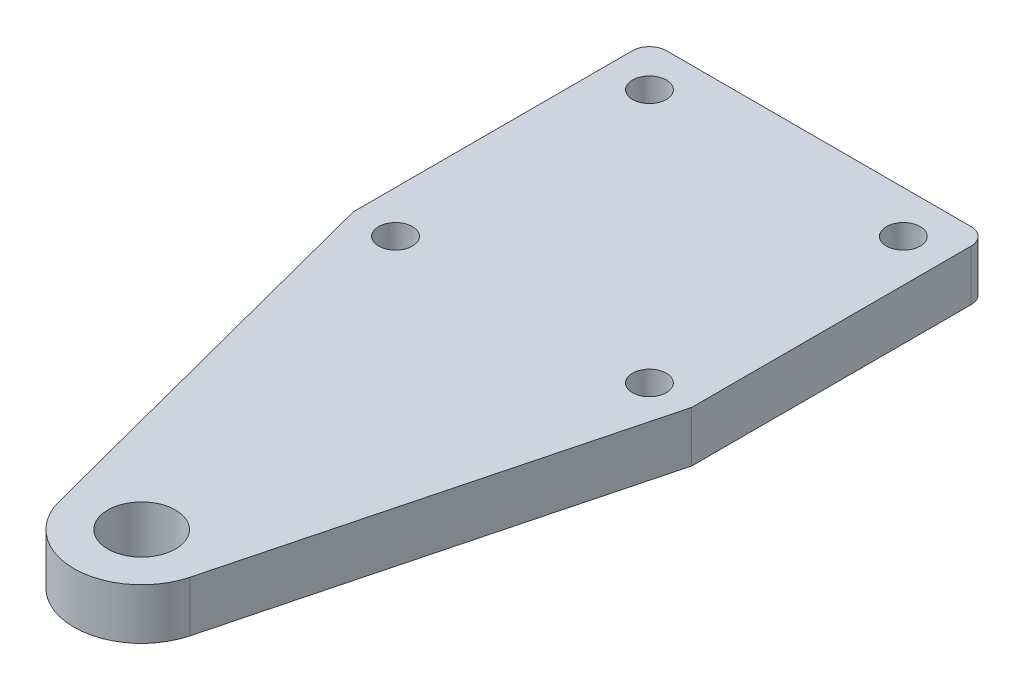
from build123d import *

# Parameters (mm, degrees)
CROQUIS1_R              = 1.000000001
CROQUIS1_R_2            = 2
SALIENTE_EXTRUIR1_DEPTH = 3


with BuildPart() as part:
    # Croquis1 → Saliente-Extruir1 (new body)
    with BuildSketch(Plane(origin=(0, 0, 0), x_dir=(1, 0, 0), z_dir=(0, 1, 0))):
        with BuildLine():
            Line((-10.000000001, -7.5), (-10.000000001, 9))
            ThreePointArc((-10.000000001, 9), (-9.707106782, 9.707106781), (-9.000000001, 10))
            Line((-9.000000001, 10), (8.999999999, 10))
            ThreePointArc((8.999999999, 10), (9.70710678, 9.707106781), (9.999999999, 9))
            Line((9.999999999, 9), (9.999999999, -7.5))
            Line((9.999999999, -7.5), (3.870607027, -31.009158679))
            ThreePointArc((3.870607027, -31.009158679), (0, -34), (-3.870607027, -31.009158679))
            Line((-3.870607027, -31.009158679), (-10.000000001, -7.5))
        make_face()
        with Locations(Location((-7.500000001, 7.5, 0), (0, 0, 270))):  # turned: the seam where the file's is
            Circle(CROQUIS1_R, mode=Mode.SUBTRACT)
        with Locations(Location((7.499999999, 7.5, 0), (0, 0, 270))):  # turned: the seam where the file's is
            Circle(CROQUIS1_R, mode=Mode.SUBTRACT)
        with Locations(Location((7.499999999, -7.5, 0), (0, 0, 270))):  # turned: the seam where the file's is
            Circle(CROQUIS1_R, mode=Mode.SUBTRACT)
        with Locations(Location((-7.500000001, -7.5, 0), (0, 0, 270))):  # turned: the seam where the file's is
            Circle(CROQUIS1_R, mode=Mode.SUBTRACT)
        with Locations(Location((0, -30, 0), (0, 0, 270))):  # turned: the seam where the file's is
            Circle(CROQUIS1_R_2, mode=Mode.SUBTRACT)
    extrude(amount=SALIENTE_EXTRUIR1_DEPTH)


solid = part.part
